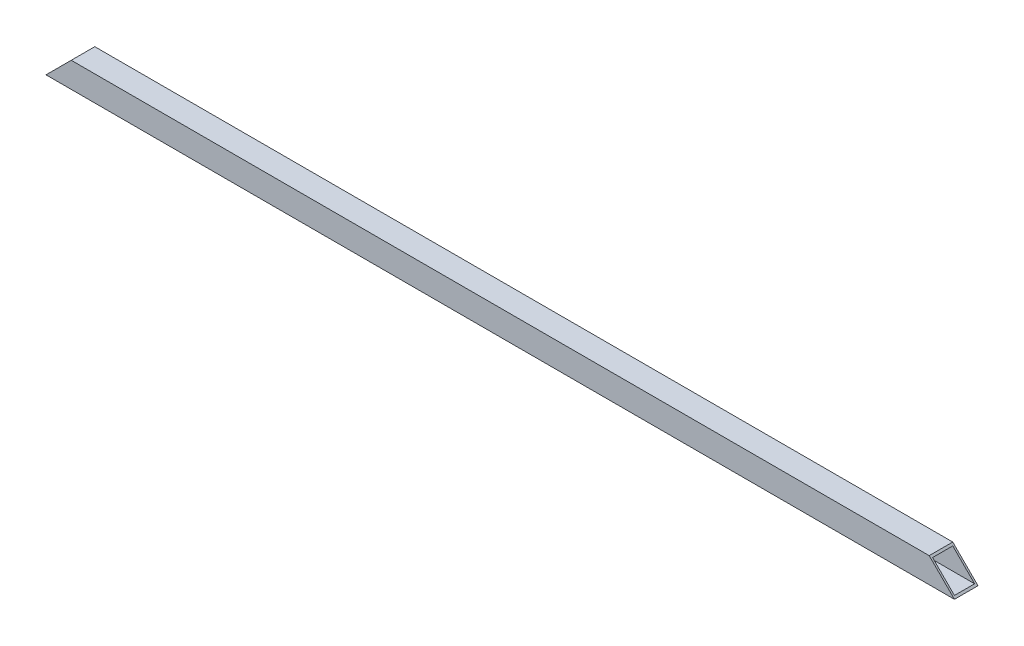
from build123d import *

# Parameters (mm, degrees)
SKETCH_2_W          = 70
SKETCH_2_H          = 75
SKETCH_2_W_2        = 60
SKETCH_2_H_2        = 65
EXTRUDE_1_DEPTH     = 2700
SKETCH_3_OUTSIDE_W  = 3242.39
SKETCH_3_OUTSIDE_H  = 617.39
CUT_EXTRUDE_1_DEPTH = 71


with BuildPart() as part:
    # Эскиз2 → Вытянуть-Тонкостенный1 (new body)
    with BuildSketch(Plane(origin=(0, 0, 0), x_dir=(0, 0, -1), z_dir=(1, 0, 0))):
        Rectangle(SKETCH_2_W, SKETCH_2_H)
        Rectangle(SKETCH_2_W_2, SKETCH_2_H_2, mode=Mode.SUBTRACT)
    extrude(amount=EXTRUDE_1_DEPTH)

    # Эскиз3 outside → Вырез-Вытянуть1 (cut, through all)
    with BuildSketch(Plane(origin=(0, 0, -35), x_dir=(-1, 0, 0), z_dir=(0, 0, -1))):
        with Locations((-1350, 0)):
            Rectangle(SKETCH_3_OUTSIDE_W, SKETCH_3_OUTSIDE_H)
        Polygon((-2700, -37.5), (-2625, 37.5), (-75, 37.5), (0, -37.5), align=None, mode=Mode.SUBTRACT)
    extrude(amount=-CUT_EXTRUDE_1_DEPTH, mode=Mode.SUBTRACT)


solid = part.part
